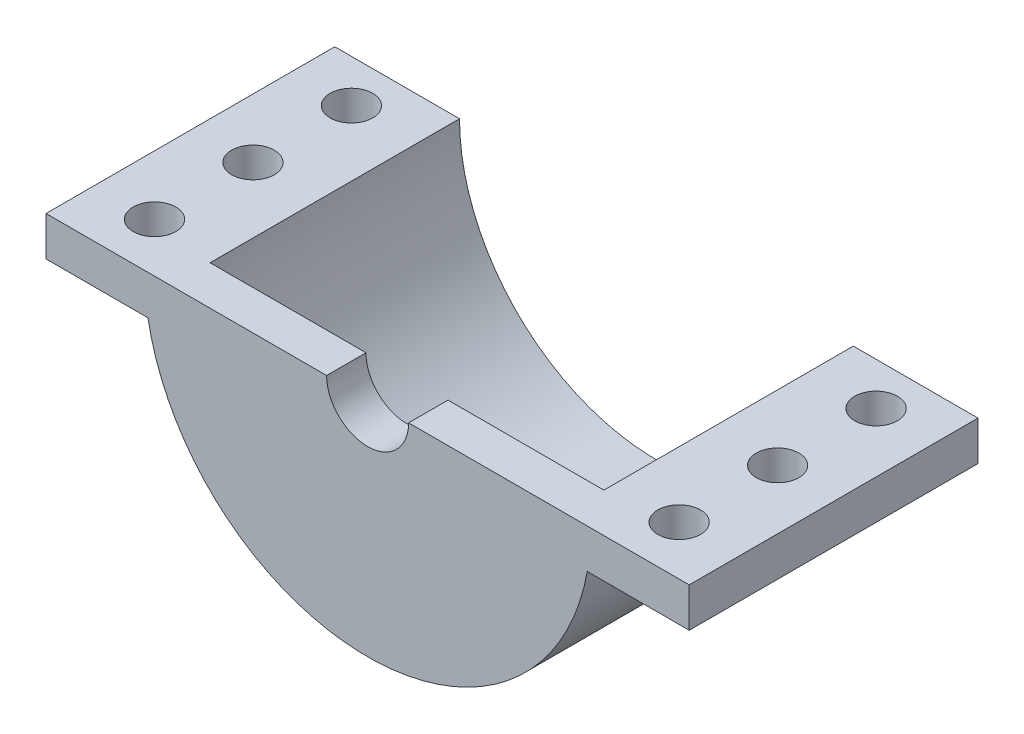
from build123d import *

# Parameters (mm, degrees)
SALIENTE_EXTRUIR1_DEPTH = 19
SALIENTE_EXTRUIR2_DEPTH = 3
CROQUIS3_R              = 3.125
CORTAR_EXTRUIR1_DEPTH   = 3
CROQUIS4_W              = 7.766799469
CROQUIS4_H              = 3
SALIENTE_EXTRUIR3_DEPTH = 22
CROQUIS5_R              = 1.625
CORTAR_EXTRUIR2_DEPTH   = 4


with BuildPart() as part:
    # Croquis1 → Saliente-Extruir1 (new body)
    with BuildSketch(Plane.XY):
        with BuildLine():
            Line((17, 0), (15, 0))
            ThreePointArc((15, 0), (0, -15), (-15, 0))
            Line((-15, 0), (-17, 0))
            ThreePointArc((-17, 0), (0, -17), (17, 0))
        make_face()
    extrude(amount=SALIENTE_EXTRUIR1_DEPTH)

    # Croquis2 → Saliente-Extruir2 (add)
    with BuildSketch(Plane.XY.offset(19)):
        with BuildLine():
            Line((15, 0), (-15, 0))
            ThreePointArc((-15, 0), (0, -15), (15, 0))
        make_face()
        with BuildLine():
            ThreePointArc((15, 0), (0, -15), (-15, 0))
            Line((-15, 0), (-17, 0))
            ThreePointArc((-17, 0), (0, -17), (17, 0))
            Line((17, 0), (15, 0))
        make_face()
    extrude(amount=SALIENTE_EXTRUIR2_DEPTH)

    # Croquis3 → Cortar-Extruir1 (cut)
    with BuildSketch(Plane.XY.offset(22)):
        Circle(CROQUIS3_R)
    extrude(amount=-CORTAR_EXTRUIR1_DEPTH, mode=Mode.SUBTRACT)

    # Croquis4 → Saliente-Extruir3 (add)
    with BuildSketch(Plane.XY.offset(22)):
        with Locations((-20.616600266, -1.5)):
            Rectangle(CROQUIS4_W, CROQUIS4_H)
        with Locations((20.616600266, -1.5)):
            Rectangle(CROQUIS4_W, CROQUIS4_H)
    extrude(amount=-SALIENTE_EXTRUIR3_DEPTH)

    # Croquis5 → Cortar-Extruir2 (cut, through all)
    with BuildSketch(Plane.XZ.offset(3)):
        with Locations((-19.983200531, 3.25)):
            Circle(CROQUIS5_R)
        with Locations((-19.983200531, 10.75)):
            Circle(CROQUIS5_R)
        with Locations((-19.983200531, 18.25)):
            Circle(CROQUIS5_R)
        with Locations((19.983200531, 18.25)):
            Circle(CROQUIS5_R)
        with Locations((19.983200531, 10.75)):
            Circle(CROQUIS5_R)
        with Locations((19.983200531, 3.25)):
            Circle(CROQUIS5_R)
    extrude(amount=-CORTAR_EXTRUIR2_DEPTH, mode=Mode.SUBTRACT)


solid = part.part
